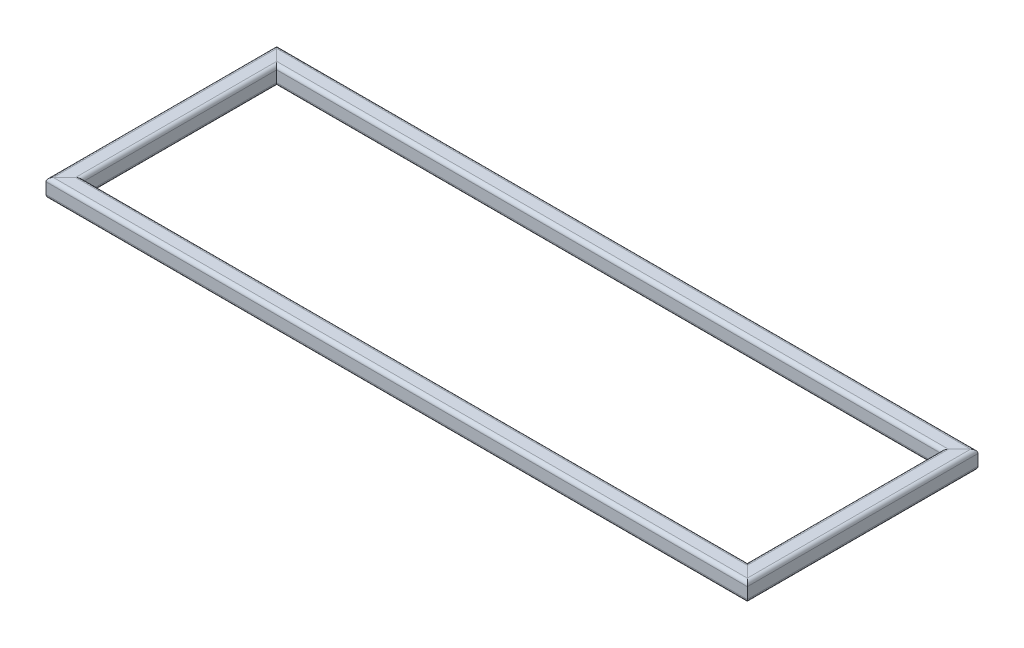
from build123d import *

# Parameters (mm, degrees)
SQUARE_TUBE_CONFIGURED_20_X_20_X_2_1_DEPTH      = 785.142135624
SQUARE_TUBE_CONFIGURED_20_X_20_X_2_1_DEPTH_BACK = 25.142135624
SQUARE_TUBE_CONFIGURED_20_X_20_X_2_1_2_DEPTH    = 300.284271247
SQUARE_TUBE_CONFIGURED_20_X_20_X_2_1_3_DEPTH    = 810.284271247
SQUARE_TUBE_CONFIGURED_20_X_20_X_2_1_4_DEPTH    = 300.284271247


with BuildPart() as part:
    # Sketch11 → Square tube - configured 20 X 20 X 2(1) (new, two sides)
    with BuildSketch(Plane(origin=(380, 0, -115), x_dir=(0, 0, 1), z_dir=(-1, 0, 0))) as square_tube_configured_20_x_20_x_2_1_sk:
        with BuildLine():
            Line((-6, -10), (6, -10))
            ThreePointArc((6, -10), (8.828427125, -8.828427125), (10, -6))
            Line((10, -6), (10, 6))
            ThreePointArc((10, 6), (8.828427125, 8.828427125), (6, 10))
            Line((6, 10), (-6, 10))
            ThreePointArc((-6, 10), (-8.828427125, 8.828427125), (-10, 6))
            Line((-10, 6), (-10, -6))
            ThreePointArc((-10, -6), (-8.828427125, -8.828427125), (-6, -10))
        make_face()
        with BuildLine():
            Line((-6, -8), (6, -8))
            ThreePointArc((6, -8), (7.414213562, -7.414213562), (8, -6))
            Line((8, -6), (8, 6))
            ThreePointArc((8, 6), (7.414213562, 7.414213562), (6, 8))
            Line((6, 8), (-6, 8))
            ThreePointArc((-6, 8), (-7.414213562, 7.414213562), (-8, 6))
            Line((-8, 6), (-8, -6))
            ThreePointArc((-8, -6), (-7.414213562, -7.414213562), (-6, -8))
        make_face(mode=Mode.SUBTRACT)
    extrude(amount=SQUARE_TUBE_CONFIGURED_20_X_20_X_2_1_DEPTH)
    extrude(square_tube_configured_20_x_20_x_2_1_sk.sketch, amount=-SQUARE_TUBE_CONFIGURED_20_X_20_X_2_1_DEPTH_BACK)

    # Square tube - configured 20 X 20 X 2(1) m
    split(bisect_by=Plane(origin=(380, 0, -125), x_dir=(0, -1, 0), z_dir=(-0.707106781, 0, -0.707106781)), keep=Keep.TOP)

    # Square tube - configured 20 X 20 X 2 2
    split(bisect_by=Plane(origin=(-380, 0, -125), x_dir=(0, 1, 0), z_dir=(0.707106781, 0, -0.707106781)), keep=Keep.TOP)


with BuildPart() as body_2:
    # Sketch11 on segment 2 (carried to segment 2) → Square tube - configured 20 X 20 X 2_1 2 (new body)
    with BuildSketch(Plane(origin=(-370, 0, -150.142135624), x_dir=(1, 0, 0), z_dir=(0, 0, 1))):
        with BuildLine():
            Line((-6, -10), (6, -10))
            ThreePointArc((6, -10), (8.828427125, -8.828427125), (10, -6))
            Line((10, -6), (10, 6))
            ThreePointArc((10, 6), (8.828427125, 8.828427125), (6, 10))
            Line((6, 10), (-6, 10))
            ThreePointArc((-6, 10), (-8.828427125, 8.828427125), (-10, 6))
            Line((-10, 6), (-10, -6))
            ThreePointArc((-10, -6), (-8.828427125, -8.828427125), (-6, -10))
        make_face()
        with BuildLine():
            Line((-6, -8), (6, -8))
            ThreePointArc((6, -8), (7.414213562, -7.414213562), (8, -6))
            Line((8, -6), (8, 6))
            ThreePointArc((8, 6), (7.414213562, 7.414213562), (6, 8))
            Line((6, 8), (-6, 8))
            ThreePointArc((-6, 8), (-7.414213562, 7.414213562), (-8, 6))
            Line((-8, 6), (-8, -6))
            ThreePointArc((-8, -6), (-7.414213562, -7.414213562), (-6, -8))
        make_face(mode=Mode.SUBTRACT)
    extrude(amount=SQUARE_TUBE_CONFIGURED_20_X_20_X_2_1_2_DEPTH)

    # Square tube - configured 20 X 20 X 2 3
    split(bisect_by=Plane(origin=(-380, 0, 125), x_dir=(0, -1, 0), z_dir=(-0.707106781, 0, -0.707106781)), keep=Keep.TOP)

    # Square tube - configured 20 X 20 X 2 4
    split(bisect_by=Plane(origin=(-380, 0, -125), x_dir=(0, -1, 0), z_dir=(-0.707106781, 0, 0.707106781)), keep=Keep.TOP)


with BuildPart() as body_3:
    # Sketch11 on segment 3 (carried to segment 3) → Square tube - configured 20 X 20 X 2_1 3 (new body)
    with BuildSketch(Plane(origin=(-405.142135624, 0, 115), x_dir=(0, 0, -1), z_dir=(1, 0, 0))):
        with BuildLine():
            Line((-6, -10), (6, -10))
            ThreePointArc((6, -10), (8.828427125, -8.828427125), (10, -6))
            Line((10, -6), (10, 6))
            ThreePointArc((10, 6), (8.828427125, 8.828427125), (6, 10))
            Line((6, 10), (-6, 10))
            ThreePointArc((-6, 10), (-8.828427125, 8.828427125), (-10, 6))
            Line((-10, 6), (-10, -6))
            ThreePointArc((-10, -6), (-8.828427125, -8.828427125), (-6, -10))
        make_face()
        with BuildLine():
            Line((-6, -8), (6, -8))
            ThreePointArc((6, -8), (7.414213562, -7.414213562), (8, -6))
            Line((8, -6), (8, 6))
            ThreePointArc((8, 6), (7.414213562, 7.414213562), (6, 8))
            Line((6, 8), (-6, 8))
            ThreePointArc((-6, 8), (-7.414213562, 7.414213562), (-8, 6))
            Line((-8, 6), (-8, -6))
            ThreePointArc((-8, -6), (-7.414213562, -7.414213562), (-6, -8))
        make_face(mode=Mode.SUBTRACT)
    extrude(amount=SQUARE_TUBE_CONFIGURED_20_X_20_X_2_1_3_DEPTH)

    # Square tube - configured 20 X 20 X 2 5
    split(bisect_by=Plane(origin=(380, 0, 125), x_dir=(0, -1, 0), z_dir=(-0.707106781, 0, 0.707106781)), keep=Keep.TOP)

    # Square tube - configured 20 X 20 X 2 6
    split(bisect_by=Plane(origin=(-380, 0, 125), x_dir=(0, 1, 0), z_dir=(0.707106781, 0, 0.707106781)), keep=Keep.TOP)


with BuildPart() as body_4:
    # Sketch11 on segment 4 (carried to segment 4) → Square tube - configured 20 X 20 X 2_1 4 (new body)
    with BuildSketch(Plane(origin=(370, 0, 150.142135624), x_dir=(-1, 0, 0), z_dir=(0, 0, -1))):
        with BuildLine():
            Line((-6, -10), (6, -10))
            ThreePointArc((6, -10), (8.828427125, -8.828427125), (10, -6))
            Line((10, -6), (10, 6))
            ThreePointArc((10, 6), (8.828427125, 8.828427125), (6, 10))
            Line((6, 10), (-6, 10))
            ThreePointArc((-6, 10), (-8.828427125, 8.828427125), (-10, 6))
            Line((-10, 6), (-10, -6))
            ThreePointArc((-10, -6), (-8.828427125, -8.828427125), (-6, -10))
        make_face()
        with BuildLine():
            Line((-6, -8), (6, -8))
            ThreePointArc((6, -8), (7.414213562, -7.414213562), (8, -6))
            Line((8, -6), (8, 6))
            ThreePointArc((8, 6), (7.414213562, 7.414213562), (6, 8))
            Line((6, 8), (-6, 8))
            ThreePointArc((-6, 8), (-7.414213562, 7.414213562), (-8, 6))
            Line((-8, 6), (-8, -6))
            ThreePointArc((-8, -6), (-7.414213562, -7.414213562), (-6, -8))
        make_face(mode=Mode.SUBTRACT)
    extrude(amount=SQUARE_TUBE_CONFIGURED_20_X_20_X_2_1_4_DEPTH)

    # Square tube - configured 20 X 20 X 2 7
    split(bisect_by=Plane(origin=(380, 0, 125), x_dir=(0, 1, 0), z_dir=(0.707106781, 0, -0.707106781)), keep=Keep.TOP)

    # Square tube - configured 20 X 20 X 2 8
    split(bisect_by=Plane(origin=(380, 0, -125), x_dir=(0, 1, 0), z_dir=(0.707106781, 0, 0.707106781)), keep=Keep.TOP)


solid = Compound([part.part, body_2.part, body_3.part, body_4.part])
